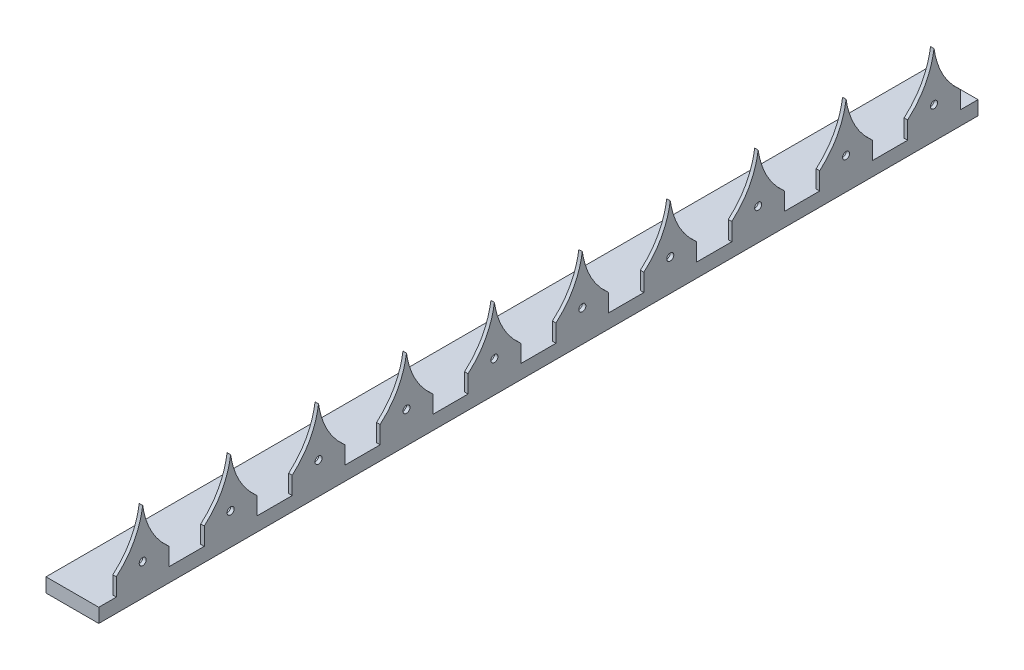
from build123d import *

# Parameters (mm, degrees)
SKETCH1_W           = 30
SKETCH1_H           = 8
BOSS_EXTRUDE1_DEPTH = 50
SKETCH2_R           = 2
BOSS_EXTRUDE2_DEPTH = 2
LPATTERN1_COUNT     = 10
LPATTERN1_PITCH     = 50


with BuildPart() as part:
    # Sketch1 → Boss-Extrude1 (new body)
    with BuildSketch(Plane.XY):
        Rectangle(SKETCH1_W, SKETCH1_H)
    boss_extrude1 = extrude(amount=BOSS_EXTRUDE1_DEPTH)

    # Sketch2 → Boss-Extrude2 (add)
    with BuildSketch(Plane(origin=(15, 0, 0), x_dir=(0, 0, -1), z_dir=(1, 0, 0))):
        with BuildLine():
            Line((-40, 14), (-40, 4))
            Line((-40, 4), (-10, 4))
            Line((-10, 4), (-10, 14))
            add(Edge.make_bspline(
                [(-10, 14), (-22.549212794, 24.931170197), (-25, 41.661304797)],
                knots=[0, 0, 0, 1, 1, 1], degree=2))
            add(Edge.make_bspline(
                [(-40, 14), (-27.450787206, 24.931170197), (-25, 41.661304797)],
                knots=[0, 0, 0, 1, 1, 1], degree=2))
        make_face()
        with Locations((-25, 14)):
            Circle(SKETCH2_R, mode=Mode.SUBTRACT)
    boss_extrude2 = extrude(amount=-BOSS_EXTRUDE2_DEPTH)

    # LPattern1: Boss-Extrude1, Boss-Extrude2 ×10
    with Locations(*[(0, 0, i * LPATTERN1_PITCH) for i in range(1, LPATTERN1_COUNT)]):
        add(boss_extrude1)
        add(boss_extrude2)


solid = part.part
